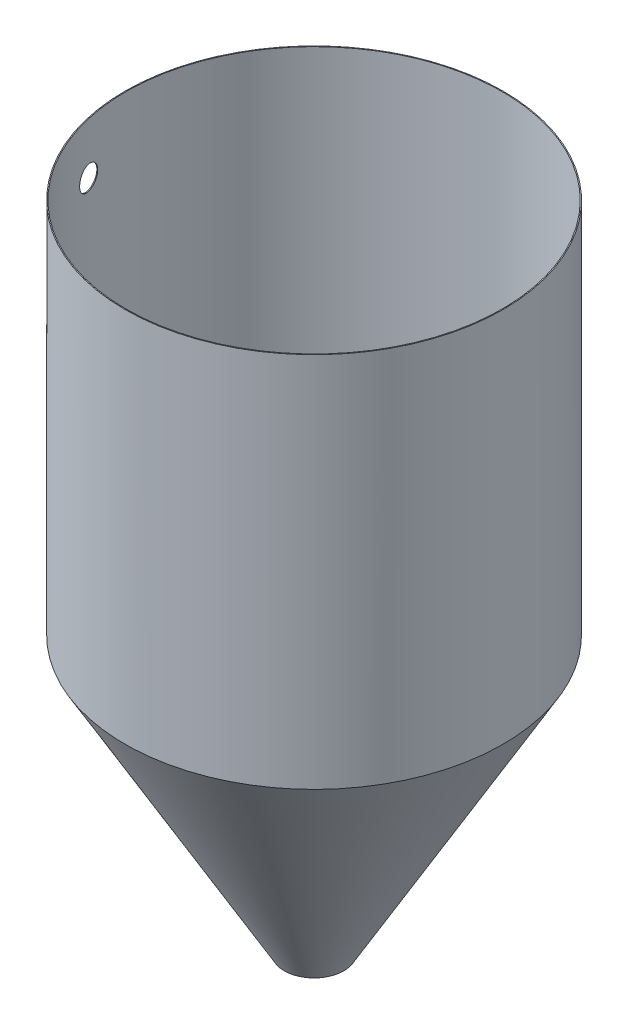
from build123d import *

# Parameters (mm, degrees)
SKETCH1_R           = 255.21412
SKETCH1_R_2         = 254
BOSS_EXTRUDE1_DEPTH = 508
SKETCH3_R           = 15.875
CUT_EXTRUDE1_DEPTH  = 304.8


with BuildPart() as part:
    # Sketch1 → Boss-Extrude1 (new body)
    with BuildSketch(Plane(origin=(0, 0, 0), x_dir=(1, 0, 0), z_dir=(0, 1, 0))):
        Circle(SKETCH1_R)
        Circle(SKETCH1_R_2, mode=Mode.SUBTRACT)
    extrude(amount=BOSS_EXTRUDE1_DEPTH)

    # Sketch2 → Revolve1 (revolve)
    with BuildSketch(Plane.XY):
        Polygon((254, 0), (38.989, -372.409976186), (40.20312, -372.409976186), (255.21412, 0), align=None)
    revolve(axis=Axis((0, -439.940905122, 0), (0, 1, 0)))

    # Sketch3 → Cut-Extrude1 (cut)
    with BuildSketch(Plane(origin=(0, 53.975, 0), x_dir=(0, 0, -1), z_dir=(1, 0, 0))):
        with Locations((-57.15, 384.980800527)):
            Circle(SKETCH3_R)
    extrude(amount=-CUT_EXTRUDE1_DEPTH, mode=Mode.SUBTRACT)


solid = part.part
